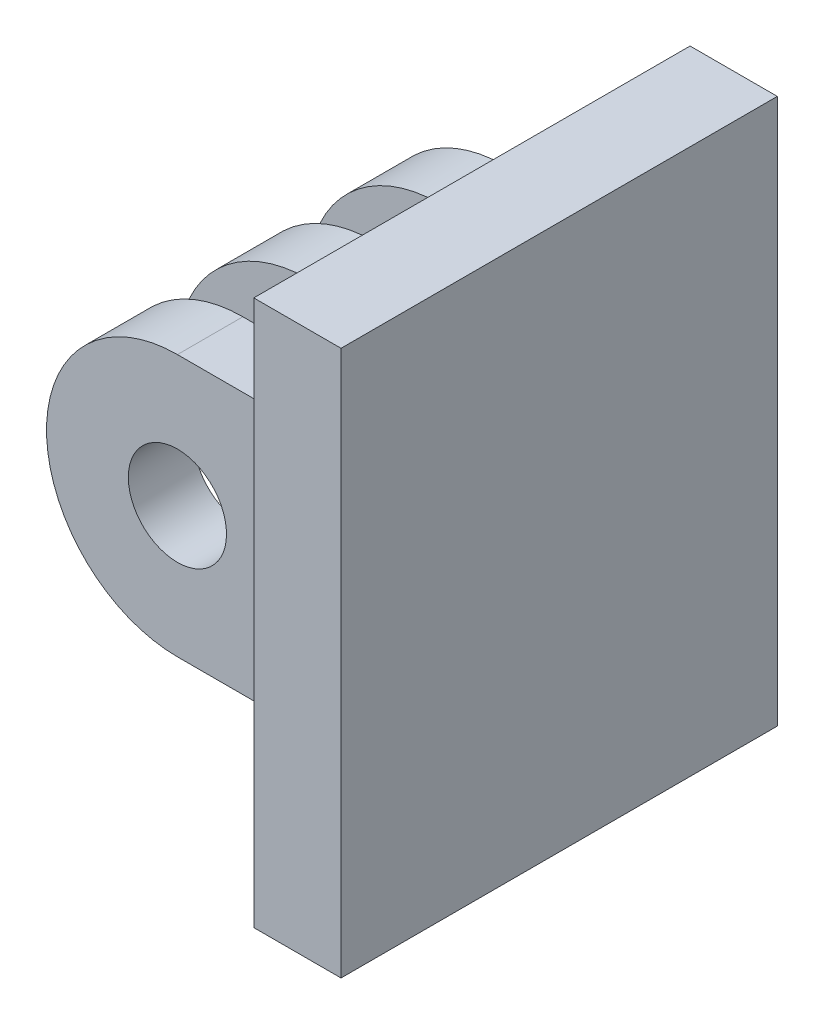
from build123d import *

# Parameters (mm, degrees)
SKETCH1_W           = 20
SKETCH1_H           = 25
BOSS_EXTRUDE1_DEPTH = 4
SKETCH2_W           = 3
SKETCH2_H           = 12
BOSS_EXTRUDE2_DEPTH = 12
SKETCH3_R           = 2.25
CUT_EXTRUDE1_DEPTH  = 18.5
CHAMFER1_SIZE       = 0.75


with BuildPart() as part:
    # Sketch1 → Boss-Extrude1 (new body)
    with BuildSketch(Plane(origin=(0, 0, 0), x_dir=(0, 0, -1), z_dir=(1, 0, 0))):
        with Locations((10, -12.5)):
            Rectangle(SKETCH1_W, SKETCH1_H)
    extrude(amount=BOSS_EXTRUDE1_DEPTH)

    # Sketch2 → Boss-Extrude2 (add)
    with BuildSketch(Plane.ZY):
        with Locations((-10, -12.5)):
            Rectangle(SKETCH2_W, SKETCH2_H)
        with Locations((-4, -12.5)):
            Rectangle(SKETCH2_W, SKETCH2_H)
        with Locations((-16, -12.5)):
            Rectangle(SKETCH2_W, SKETCH2_H)
    extrude(amount=BOSS_EXTRUDE2_DEPTH)

    # Sketch3 → Cut-Extrude1 (cut, through all)
    with BuildSketch(Plane(origin=(0, 0, -17.5), x_dir=(-1, 0, 0), z_dir=(0, 0, -1))):
        with Locations((6, -12.5)):
            Circle(SKETCH3_R)
        with BuildLine():
            Line((12, -6.5), (6, -6.5))
            ThreePointArc((6, -6.5), (10.242640687, -8.257359313), (12, -12.5))
            Line((12, -12.5), (12, -6.5))
        make_face()
        with BuildLine():
            Line((12, -18.5), (12, -12.5))
            ThreePointArc((12, -12.5), (10.242640687, -16.742640687), (6, -18.5))
            Line((6, -18.5), (12, -18.5))
        make_face()
    extrude(amount=-CUT_EXTRUDE1_DEPTH, mode=Mode.SUBTRACT)

    # Chamfer1
    chamfer1_edges = [part.edges().sort_by_distance(p)[0] for p in [
        (-3.75, -12.5, -17.5),
    ]]
    chamfer(chamfer1_edges, length=CHAMFER1_SIZE)


solid = part.part
